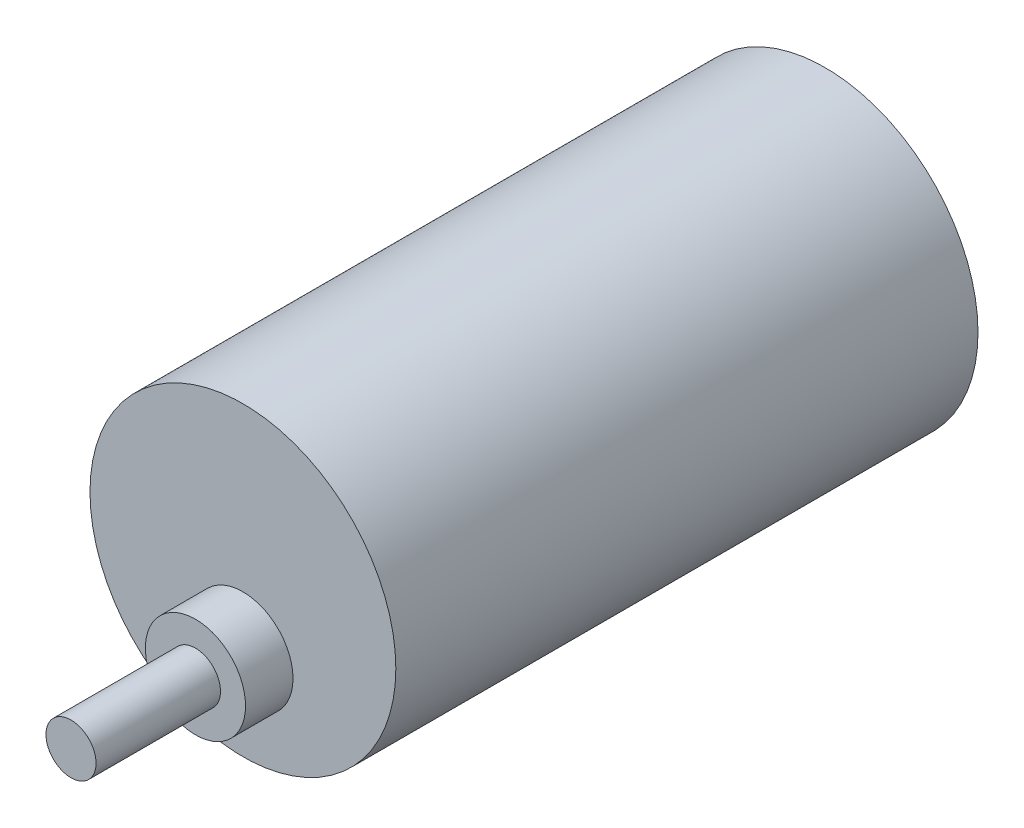
from build123d import *

# Parameters (mm, degrees)
SKETCH2_R           = 18.415
BOSS_EXTRUDE1_DEPTH = 70.104
SKETCH3_R           = 6.0325
BOSS_EXTRUDE2_DEPTH = 5.715
SKETCH5_R           = 3.01625
BOSS_EXTRUDE3_DEPTH = 14.986


with BuildPart() as part:
    # Sketch2 → Boss-Extrude1 (new body)
    with BuildSketch(Plane.XY):
        Circle(SKETCH2_R)
    extrude(amount=BOSS_EXTRUDE1_DEPTH)

    # Sketch3 → Boss-Extrude2 (add)
    with BuildSketch(Plane.XY.offset(70.104)):
        with Locations((0, -7.239)):
            Circle(SKETCH3_R)
    extrude(amount=BOSS_EXTRUDE2_DEPTH)

    # Sketch5 → Boss-Extrude3 (add)
    with BuildSketch(Plane.XY.offset(75.819)):
        with Locations((0, -7.239)):
            Circle(SKETCH5_R)
    extrude(amount=BOSS_EXTRUDE3_DEPTH)


solid = part.part
